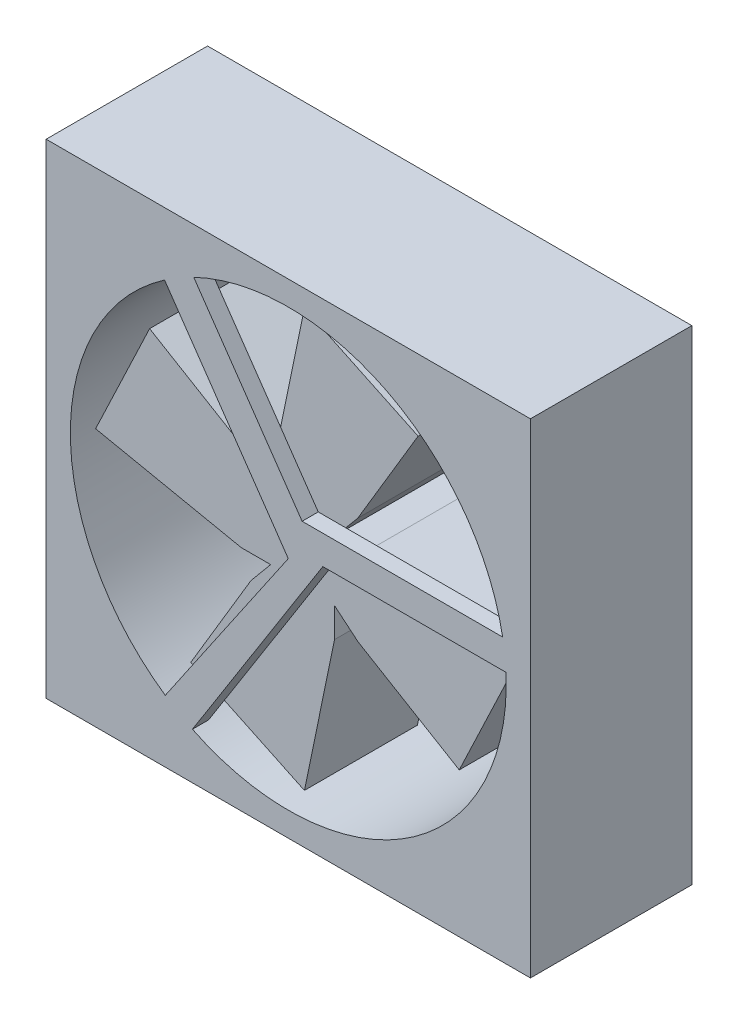
from build123d import *

# Parameters (mm, degrees)
SKETCH_1_W      = 30
SKETCH_1_H      = 30
SKETCH_1_R      = 13.5
EXTRUDE_1_DEPTH = 10
EXTRUDE_2_DEPTH = 1
EXTRUDE_3_DEPTH = 7


with BuildPart() as part:
    # 草图1 → 凸台-拉伸1 (new body)
    with BuildSketch(Plane.XY):
        with Locations((-25.822727996, 31.492551329)):
            Rectangle(SKETCH_1_W, SKETCH_1_H)
        with Locations((-25.822727996, 31.492551329)):
            Circle(SKETCH_1_R, mode=Mode.SUBTRACT)
    extrude(amount=EXTRUDE_1_DEPTH)

    # 草图2 → 凸台-拉伸2 (add)
    with BuildSketch(Plane.XY.offset(10)):
        Polygon((-32.397789449, 44.701032769), (-24.966802837, 33.924156896), (-11.116377527, 33.924156896), (-11.116377527, 32.134495199), (-23.682915097, 32.134495199), (-32.397789449, 18.361881267), (-34.074436385, 19.422810401), (-25.822727996, 31.492551329), (-34.373088606, 43.892812528), (-32.550272533, 45.149700145), align=None)
    extrude(amount=-EXTRUDE_2_DEPTH)

    # 草图3 → 凸台-拉伸3 (add)
    with BuildSketch(Plane(origin=(0, 0, 9), x_dir=(-1, 0, 0), z_dir=(0, 0, -1))):
        Polygon((22.515744425, 34.818987745), (18.780798274, 41.082803685), (25.822727996, 44.428692946), (27.690201072, 35.402573081), (27.690201072, 33.583732117), (29.149164412, 34.7995349), (35.412980353, 38.534481051), (38.758869613, 31.492551329), (29.732749748, 29.625078253), (27.913908784, 29.625078253), (29.129711567, 28.166114913), (32.864657718, 21.902298973), (25.822727996, 18.556409712), (23.955254921, 27.582529577), (23.955254921, 29.401370541), (22.49629158, 28.185567758), (16.23247564, 24.450621607), (12.886586379, 31.492551329), (21.912706244, 33.360024404), (23.731547209, 33.360024404), align=None)
    extrude(amount=EXTRUDE_3_DEPTH)


solid = part.part
